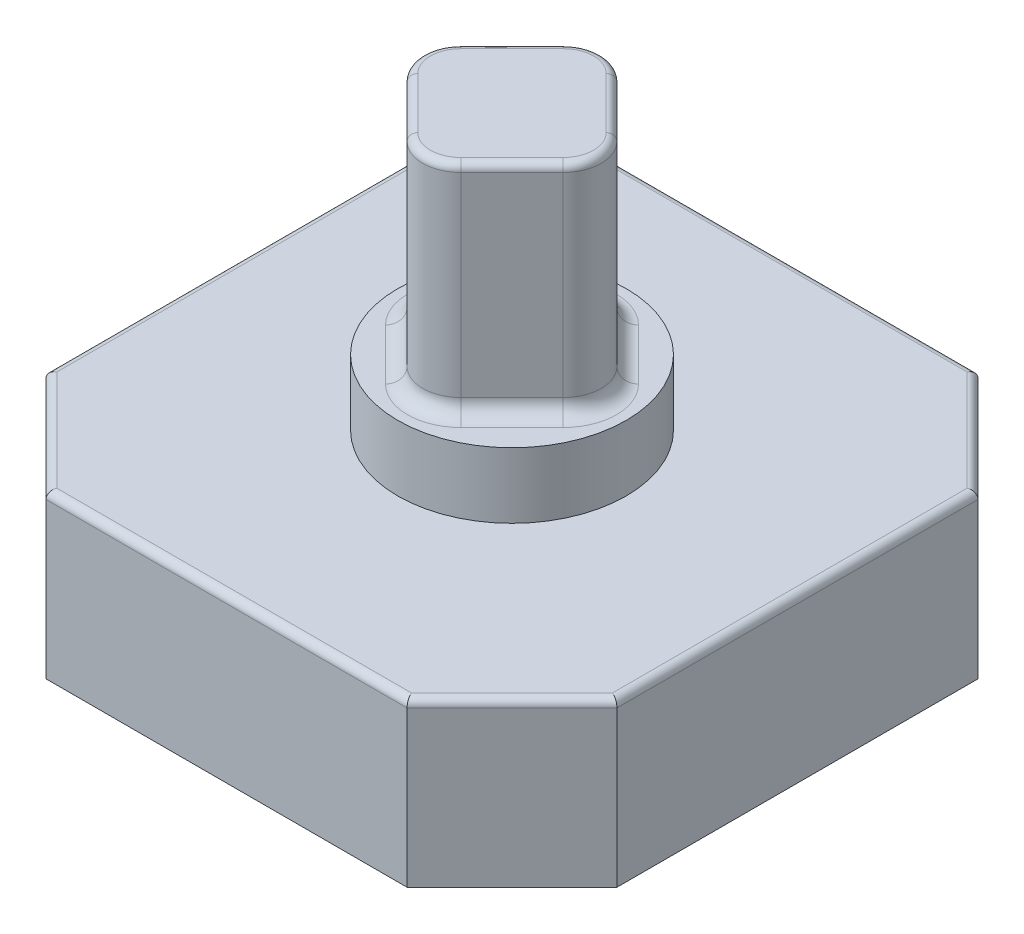
from build123d import *

# Parameters (mm, degrees)
BOSS_EXTRUDE1_DEPTH = 2.14
FILLET1_R           = 0.1
SKETCH2_R           = 1.5
BOSS_EXTRUDE2_DEPTH = 0.86
BOSS_EXTRUDE3_DEPTH = 2.86
FILLET2_R           = 0.1
FILLET3_R           = 0.2


with BuildPart() as part:
    # Sketch1 → Boss-Extrude1 (new body)
    with BuildSketch(Plane(origin=(0, 0, 0), x_dir=(1, 0, 0), z_dir=(0, 1, 0))):
        Polygon((2.371141777, -3.75), (3.75, -2.371141777), (3.75, 2.371141777), (2.371141777, 3.75), (-2.371141777, 3.75), (-3.75, 2.371141777), (-3.75, -2.371141777), (-2.371141777, -3.75), align=None)
    extrude(amount=BOSS_EXTRUDE1_DEPTH)

    # Fillet1
    fillet1_edges = [part.edges().sort_by_distance(p)[0] for p in [
        (3.75, 2.14, 0),
        (3.060570888, 2.14, -3.060570888),
        (0, 2.14, -3.75),
        (-3.060570888, 2.14, -3.060570888),
        (-3.75, 2.14, 0),
        (-3.060570888, 2.14, 3.060570888),
        (0, 2.14, 3.75),
        (3.060570888, 2.14, 3.060570888),
    ]]
    fillet(fillet1_edges, radius=FILLET1_R)

    # Sketch2 → Boss-Extrude2 (add)
    with BuildSketch(Plane(origin=(0, 2.14, 0), x_dir=(1, 0, 0), z_dir=(0, 1, 0))):
        Circle(SKETCH2_R)
    extrude(amount=BOSS_EXTRUDE2_DEPTH)

    # Sketch3 → Boss-Extrude3 (add)
    with BuildSketch(Plane(origin=(0, 3, 0), x_dir=(1, 0, 0), z_dir=(0, 1, 0))):
        with BuildLine():
            Line((-0.353553391, 1.025304833), (-1.025304833, 0.353553391))
            ThreePointArc((-1.025304833, 0.353553391), (-1.171751442, 0), (-1.025304833, -0.353553391))
            Line((-1.025304833, -0.353553391), (-0.353553391, -1.025304833))
            ThreePointArc((-0.353553391, -1.025304833), (0, -1.171751442), (0.353553391, -1.025304833))
            Line((0.353553391, -1.025304833), (1.025304833, -0.353553391))
            ThreePointArc((1.025304833, -0.353553391), (1.171751442, 0), (1.025304833, 0.353553391))
            Line((1.025304833, 0.353553391), (0.353553391, 1.025304833))
            ThreePointArc((0.353553391, 1.025304833), (0, 1.171751442), (-0.353553391, 1.025304833))
        make_face()
    extrude(amount=BOSS_EXTRUDE3_DEPTH)

    # Fillet2
    fillet2_edges = [part.edges().sort_by_distance(p)[0] for p in [
        (-1.171751442, 5.86, 0),
        (-0.689429112, 5.86, 0.689429112),
        (0, 5.86, 1.171751442),
        (0.689429112, 5.86, 0.689429112),
        (1.171751442, 5.86, 0),
        (0.689429112, 5.86, -0.689429112),
        (0, 5.86, -1.171751442),
        (-0.689429112, 5.86, -0.689429112),
    ]]
    fillet(fillet2_edges, radius=FILLET2_R)

    # Fillet3
    fillet3_edges = [part.edges().sort_by_distance(p)[0] for p in [
        (-1.171751442, 3, 0),
        (-0.689429112, 3, 0.689429112),
        (0, 3, 1.171751442),
        (0.689429112, 3, 0.689429112),
        (1.171751442, 3, 0),
        (0.689429112, 3, -0.689429112),
        (0, 3, -1.171751442),
        (-0.689429112, 3, -0.689429112),
    ]]
    fillet(fillet3_edges, radius=FILLET3_R)


solid = part.part
